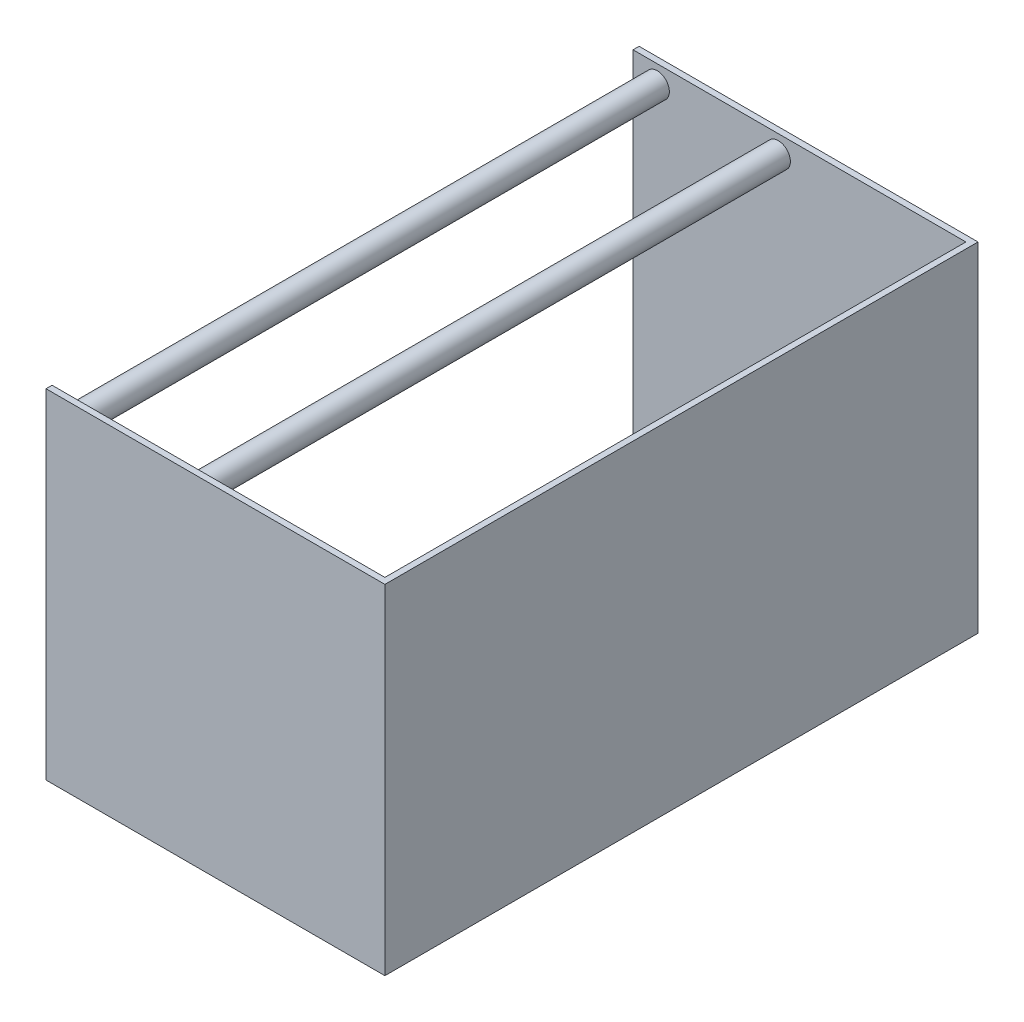
from build123d import *

# Parameters (mm, degrees)
SKETCH1_W           = 355.6
SKETCH1_H           = 622.3
BOSS_EXTRUDE1_DEPTH = 355.6
SHELL1_T            = -6.35
SKETCH2_R           = 12.7
BOSS_EXTRUDE2_DEPTH = 622.3


with BuildPart() as part:
    # Sketch1 → Boss-Extrude1 (new body)
    with BuildSketch(Plane(origin=(0, 0, 0), x_dir=(1, 0, 0), z_dir=(0, 1, 0))):
        with Locations((177.8, 311.15)):
            Rectangle(SKETCH1_W, SKETCH1_H)
    extrude(amount=BOSS_EXTRUDE1_DEPTH)

    # Shell1
    shell1_openings = [part.faces().sort_by_distance(p)[0] for p in [
        (177.8, 355.6, -311.15),
        (177.8, 0, -311.15),
        (0, 177.8, -311.15),
    ]]
    offset(amount=SHELL1_T, openings=shell1_openings, kind=Kind.INTERSECTION)

    # Sketch2 → Boss-Extrude2 (add)
    with BuildSketch(Plane(origin=(0, 0, -622.3), x_dir=(-1, 0, 0), z_dir=(0, 0, -1))):
        with Locations((-152.4, 336.55)):
            Circle(SKETCH2_R)
        with Locations((-25.4, 336.55)):
            Circle(SKETCH2_R)
    extrude(amount=-BOSS_EXTRUDE2_DEPTH)


solid = part.part
